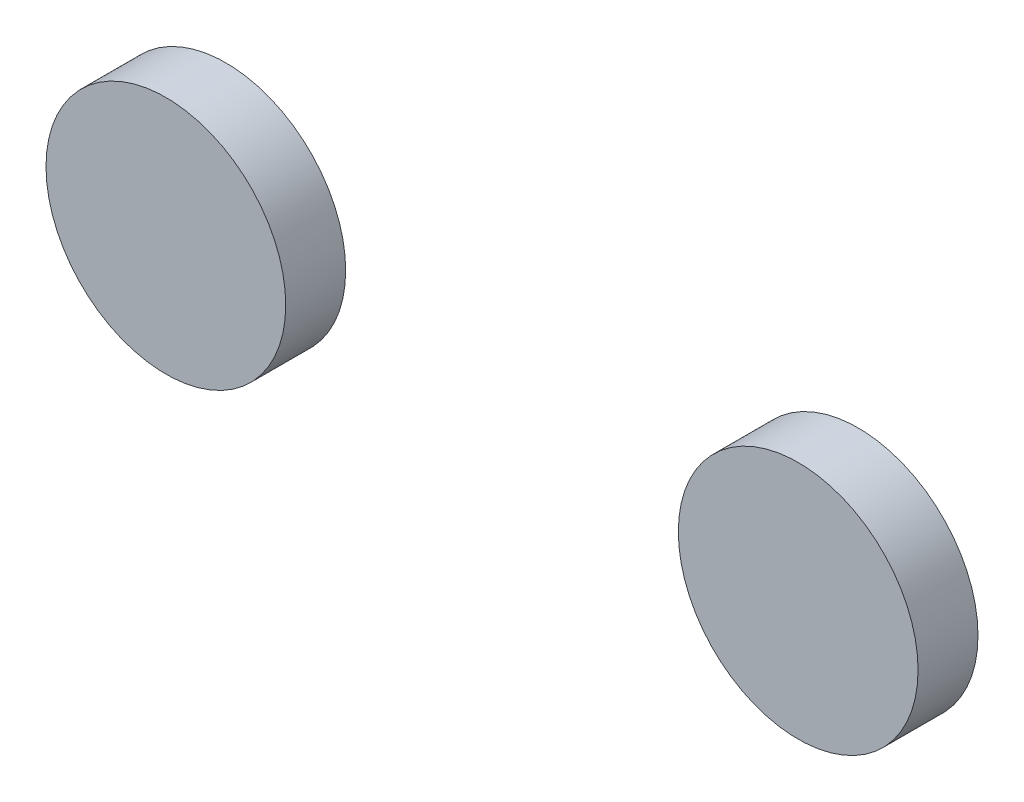
from build123d import *

# Parameters (mm, degrees)
BOSS_EXTRUDE1_DEPTH = 10


with BuildPart() as part:
    # Sketch1 → Boss-Extrude1 (new body)
    with BuildSketch(Plane.XY):
        with BuildLine():
            ThreePointArc((-31.369011051, -5.030905367), (-51.369011051, 14.969094633), (-71.369011051, -5.030905367))
            Line((-71.369011051, -5.030905367), (-31.369011051, -5.030905367))
        make_face()
        with BuildLine():
            Line((-31.369011051, -5.030905367), (-71.369011051, -5.030905367))
            ThreePointArc((-71.369011051, -5.030905367), (-51.369011051, -25.030905367), (-31.369011051, -5.030905367))
        make_face()
        with BuildLine():
            ThreePointArc((34.130988949, -5.030905367), (54.130988949, -25.030905367), (74.130988949, -5.030905367))
            Line((74.130988949, -5.030905367), (34.130988949, -5.030905367))
        make_face()
        with BuildLine():
            Line((34.130988949, -5.030905367), (74.130988949, -5.030905367))
            ThreePointArc((74.130988949, -5.030905367), (54.130988949, 14.969094633), (34.130988949, -5.030905367))
        make_face()
    extrude(amount=BOSS_EXTRUDE1_DEPTH)


solid = part.part
